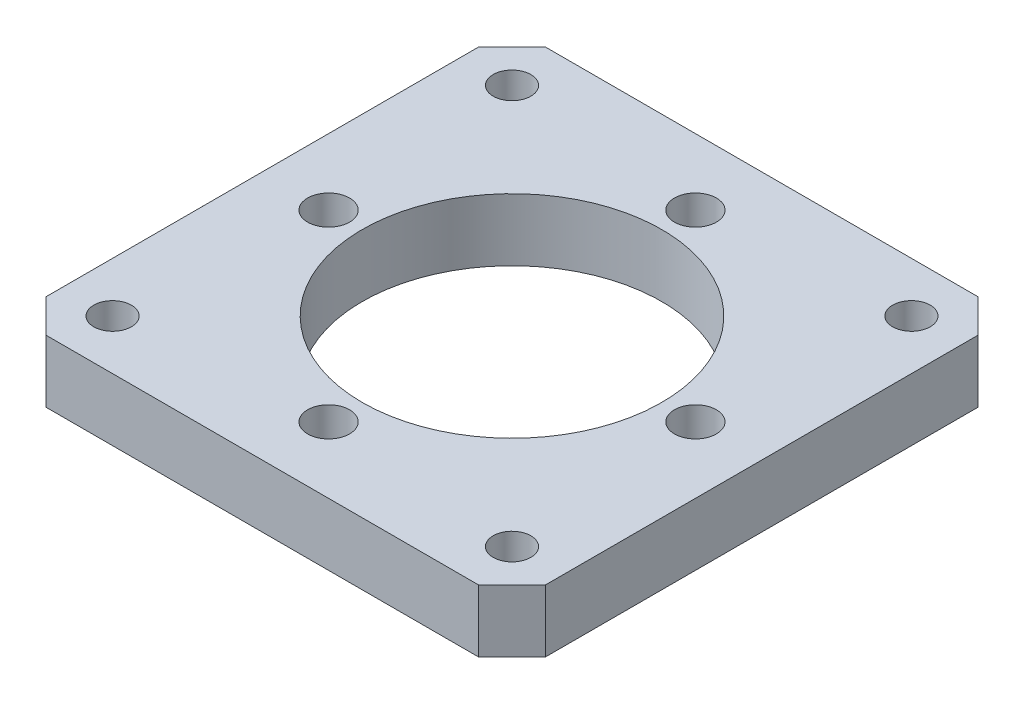
from build123d import *

# Parameters (mm, degrees)
SKETCH1_W           = 38.1
SKETCH1_H           = 38.1
SKETCH1_R           = 11.43
BOSS_EXTRUDE1_DEPTH = 4.7625
SKETCH2_R           = 1.6002
SKETCH2_R_2         = 1.4351
CUT_EXTRUDE1_DEPTH  = 5.7625
CIRPATTERN1_COUNT   = 4
CHAMFER1_SIZE       = 2.54


with BuildPart() as part:
    # Sketch1 → Boss-Extrude1 (new body)
    with BuildSketch(Plane(origin=(0, 0, 0), x_dir=(1, 0, 0), z_dir=(0, 1, 0))):
        Rectangle(SKETCH1_W, SKETCH1_H)
        Circle(SKETCH1_R, mode=Mode.SUBTRACT)
    extrude(amount=BOSS_EXTRUDE1_DEPTH)

    # Sketch2 → Cut-Extrude1 (cut, through all)
    with BuildSketch(Plane(origin=(0, 4.7625, 0), x_dir=(1, 0, 0), z_dir=(0, 1, 0))):
        with Locations((0, 13.9954)):
            Circle(SKETCH2_R)
        with Locations((15.24, 15.24)):
            Circle(SKETCH2_R_2)
    cut_extrude1 = extrude(amount=-CUT_EXTRUDE1_DEPTH, mode=Mode.SUBTRACT)

    # CirPattern1: Cut-Extrude1 ×4 about axis
    cirpattern1_axis = Axis((0, 0, 0), (0, 1, 0))
    for i in range(1, CIRPATTERN1_COUNT):
        add(cut_extrude1.rotate(cirpattern1_axis, i * 360 / CIRPATTERN1_COUNT), mode=Mode.SUBTRACT)

    # Chamfer1
    chamfer1_edges = [part.edges().sort_by_distance(p)[0] for p in [
        (19.05, 2.38125, 19.05),
        (-19.05, 2.38125, 19.05),
        (-19.05, 2.38125, -19.05),
        (19.05, 2.38125, -19.05),
    ]]
    chamfer(chamfer1_edges, length=CHAMFER1_SIZE)


solid = part.part
